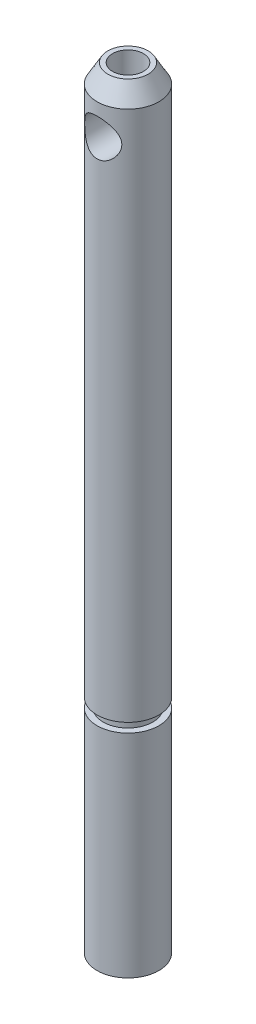
from build123d import *

# Parameters (mm, degrees)
SKETCH3_R                 = 2.5
BOSS_EXTRUDE1_DEPTH       = 62.34264779
CHAMFER1_SIZE             = 1.5
CHAMFER1_SIZE2            = 0.866025404
M3X0_5_TAPPED_HOLE1_D     = 2.5
M3X0_5_TAPPED_HOLE1_DEPTH = 4
M3X0_5_TAPPED_HOLE1_TIP   = 0.751075774
SKETCH7_R                 = 1.5
CUT_EXTRUDE1_DEPTH        = 3.5
CUT_EXTRUDE1_DEPTH_BACK   = 3.5
SKETCH8_W                 = 1
SKETCH8_H                 = 6
CUT_EXTRUDE2_DEPTH        = 3.5000001
CUT_EXTRUDE2_DEPTH_BACK   = 3.5000001
SKETCH9_R                 = 3
SKETCH9_R_2               = 2
CUT_EXTRUDE3_DEPTH        = 0.75


with BuildPart() as part:
    # Sketch3 → Boss-Extrude1 (new body)
    with BuildSketch(Plane(origin=(0, 0, 0), x_dir=(1, 0, 0), z_dir=(0, 1, 0))):
        Circle(SKETCH3_R)
    extrude(amount=BOSS_EXTRUDE1_DEPTH)

    # Chamfer1
    chamfer1_edges = [part.edges().sort_by_distance(p)[0] for p in [
        (-2.5, 62.34264779, 0),
    ]]
    chamfer1_side = [part.faces().sort_by_distance(p)[0] for p in [
        (-2.5, 31.171323895, 0),
    ]]
    chamfer(chamfer1_edges, length=CHAMFER1_SIZE, length2=CHAMFER1_SIZE2, reference=chamfer1_side[0])

    # M3x0.5 Tapped Hole1
    with Locations(Plane(origin=(0, 62.34264779, 0), x_dir=(1, 0, 0), z_dir=(0, 1, 0))):
        with Locations((0, 0)):
            Hole(M3X0_5_TAPPED_HOLE1_D / 2, depth=M3X0_5_TAPPED_HOLE1_DEPTH)
            with Locations((0, 0, -(M3X0_5_TAPPED_HOLE1_DEPTH + M3X0_5_TAPPED_HOLE1_TIP / 2))):  # 118° drill point
                Cone(0, M3X0_5_TAPPED_HOLE1_D / 2, M3X0_5_TAPPED_HOLE1_TIP, mode=Mode.SUBTRACT)

    # Sketch7 → Cut-Extrude1 (cut, two sides)
    with BuildSketch(Plane.XY) as cut_extrude1_sk:
        with Locations((0, 58.34264779)):
            Circle(SKETCH7_R)
    extrude(amount=CUT_EXTRUDE1_DEPTH, mode=Mode.SUBTRACT)
    extrude(cut_extrude1_sk.sketch, amount=-CUT_EXTRUDE1_DEPTH_BACK, mode=Mode.SUBTRACT)

    # Sketch8 → Cut-Extrude2 (cut, two sides)
    with BuildSketch(Plane.XY) as cut_extrude2_sk:
        with Locations((-2, 3)):
            Rectangle(SKETCH8_W, SKETCH8_H)
    extrude(amount=CUT_EXTRUDE2_DEPTH, mode=Mode.SUBTRACT)
    extrude(cut_extrude2_sk.sketch, amount=-CUT_EXTRUDE2_DEPTH_BACK, mode=Mode.SUBTRACT)

    # Sketch9 → Cut-Extrude3 (cut)
    with BuildSketch(Plane(origin=(0, 17.15, 0), x_dir=(1, 0, 0), z_dir=(0, 1, 0))):
        Circle(SKETCH9_R)
        Circle(SKETCH9_R_2, mode=Mode.SUBTRACT)
    extrude(amount=CUT_EXTRUDE3_DEPTH, mode=Mode.SUBTRACT)


solid = part.part
